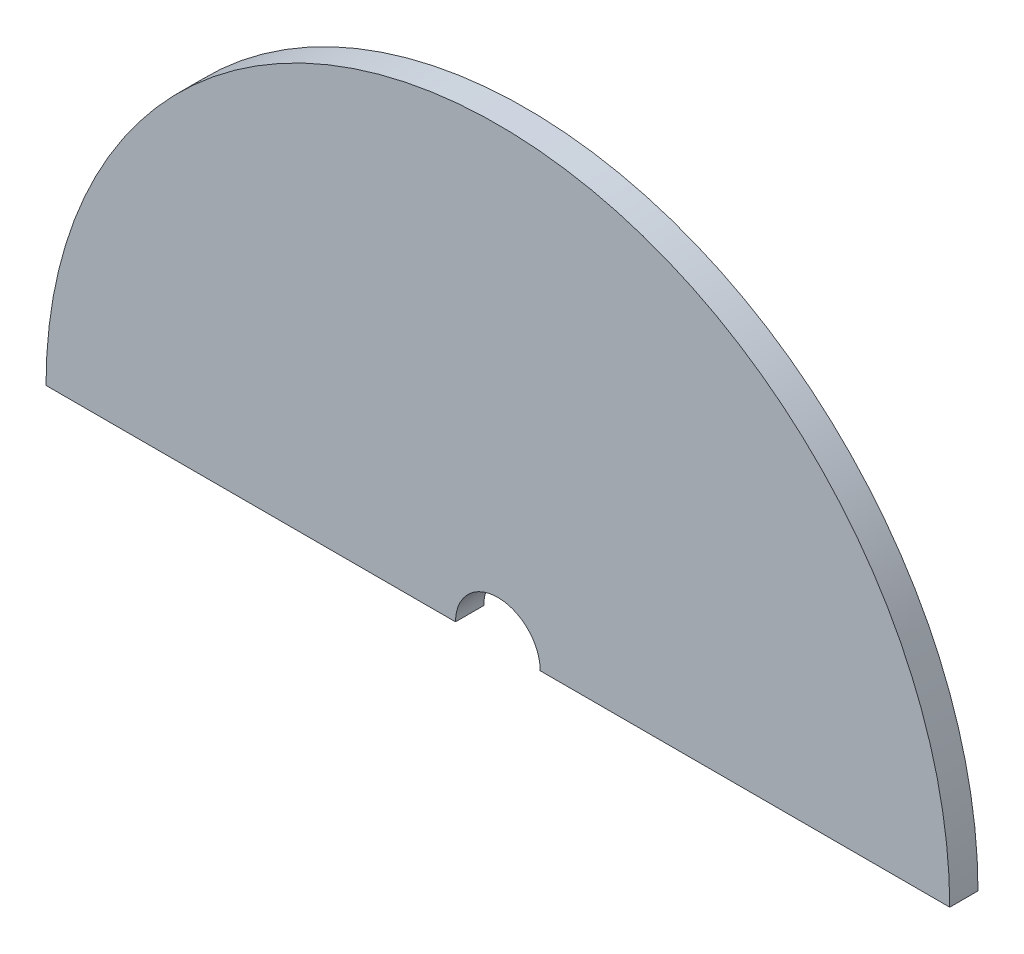
from build123d import *

# Parameters (mm, degrees)
OUTER_CASING_DEPTH = 10
SKETCH1_R          = 15
INNER_CUTOUT_DEPTH = 20


with BuildPart() as part:
    # Plate shape → Outer casing (new body)
    with BuildSketch(Plane.XY):
        with BuildLine():
            Line((0, 160), (-160, 160))
            ThreePointArc((-160, 160), (0, 320), (160, 160))
            Line((160, 160), (0, 160))
        make_face()
    extrude(amount=OUTER_CASING_DEPTH)

    # Sketch1 → Inner Cutout (cut)
    with BuildSketch(Plane.XY.offset(10)):
        with Locations((0, 160)):
            Circle(SKETCH1_R)
    extrude(amount=-INNER_CUTOUT_DEPTH, mode=Mode.SUBTRACT)


solid = part.part
